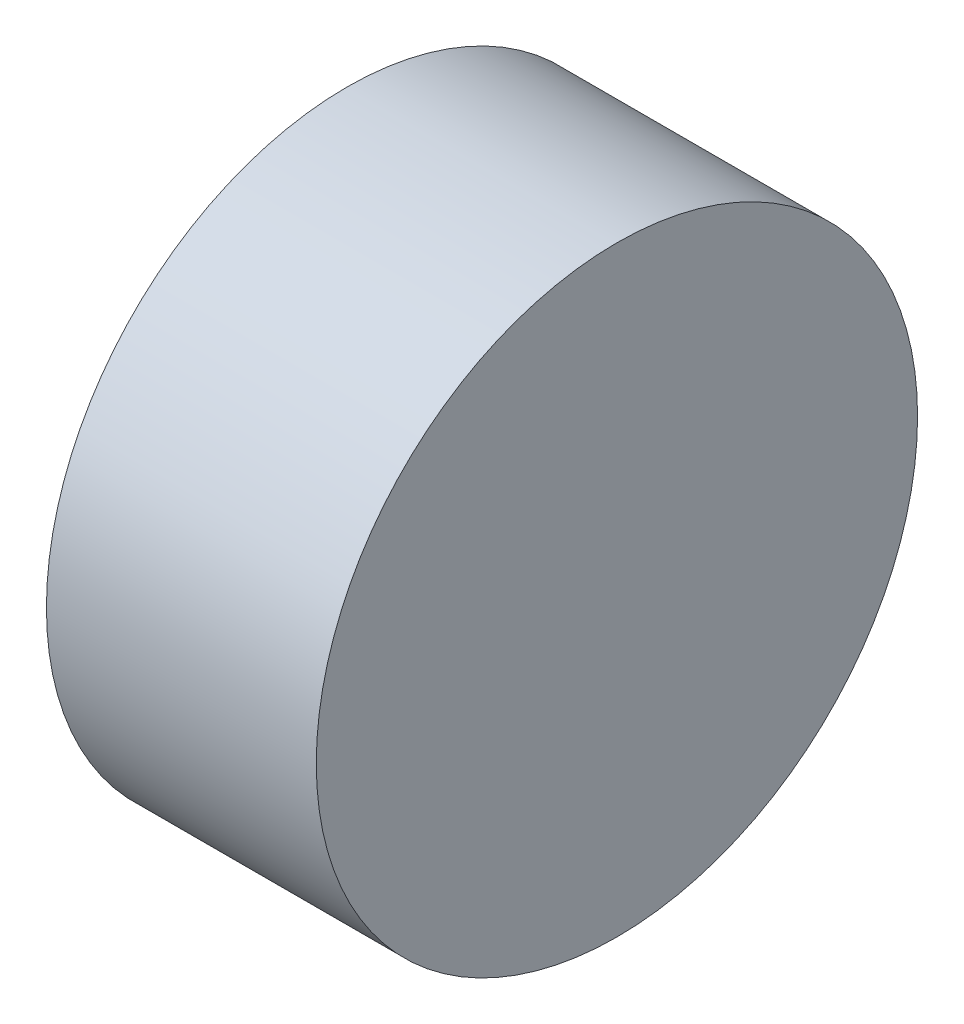
from build123d import *

# Parameters (mm, degrees)
SKETCH_1_R      = 22.282634598
EXTRUDE_1_DEPTH = 20


with BuildPart() as part:
    # 草图1 → 凸台-拉伸1 (new body)
    with BuildSketch(Plane(origin=(0, 0, 0), x_dir=(0, 0, -1), z_dir=(1, 0, 0))):
        Circle(SKETCH_1_R)
    extrude(amount=EXTRUDE_1_DEPTH)


solid = part.part
